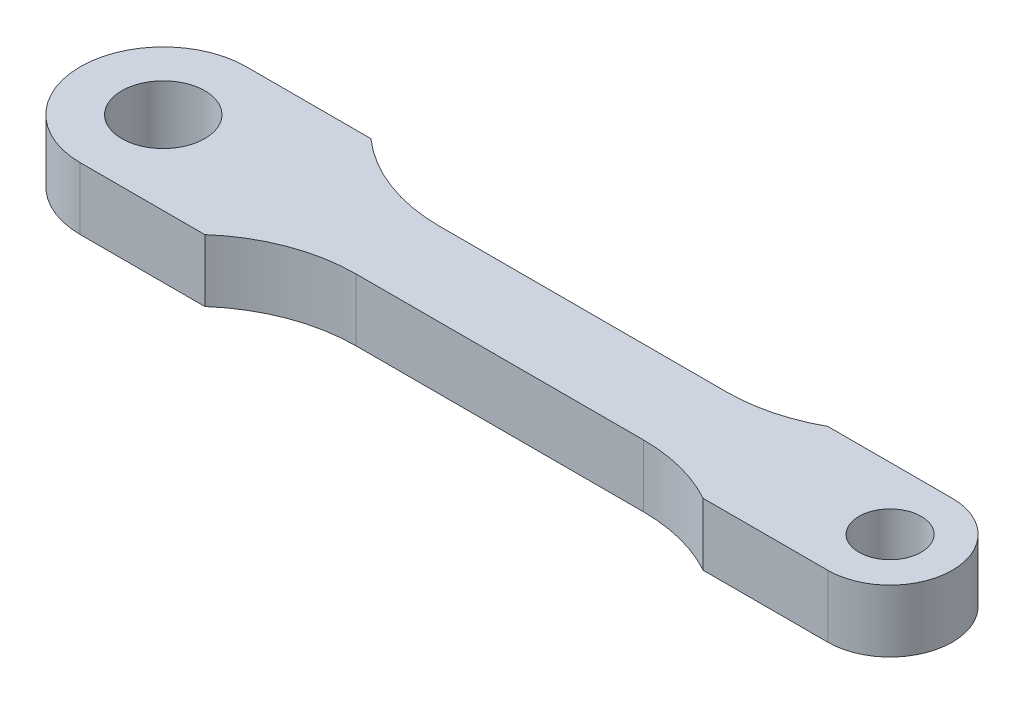
from build123d import *

# Parameters (mm, degrees)
SKETCH_1_R      = 2
SKETCH_1_R_2    = 1.5
EXTRUDE_1_DEPTH = 3


with BuildPart() as part:
    # Эскиз1 → Бобышка-Вытянуть1 (new body)
    with BuildSketch(Plane(origin=(0, 0, 0), x_dir=(1, 0, 0), z_dir=(0, 1, 0))):
        with BuildLine():
            Line((0, -4), (6, -4))
            ThreePointArc((6, -4), (8.463075497, -2.516685226), (11.291502622, -2))
            Line((11.291502622, -2), (25.127016654, -2))
            ThreePointArc((25.127016654, -2), (27.127016654, -2.254033308), (29, -3))
            Line((29, -3), (35, -3))
            ThreePointArc((35, -3), (38, 0), (35, 3))
            Line((35, 3), (29, 3))
            ThreePointArc((29, 3), (27.127016654, 2.254033308), (25.127016654, 2))
            Line((25.127016654, 2), (11.291502622, 2))
            ThreePointArc((11.291502622, 2), (8.463075497, 2.516685226), (6, 4))
            Line((6, 4), (0, 4))
            ThreePointArc((0, 4), (-4, 0), (0, -4))
        make_face()
        Circle(SKETCH_1_R, mode=Mode.SUBTRACT)
        with Locations((35, 0)):
            Circle(SKETCH_1_R_2, mode=Mode.SUBTRACT)
    extrude(amount=EXTRUDE_1_DEPTH)


solid = part.part
